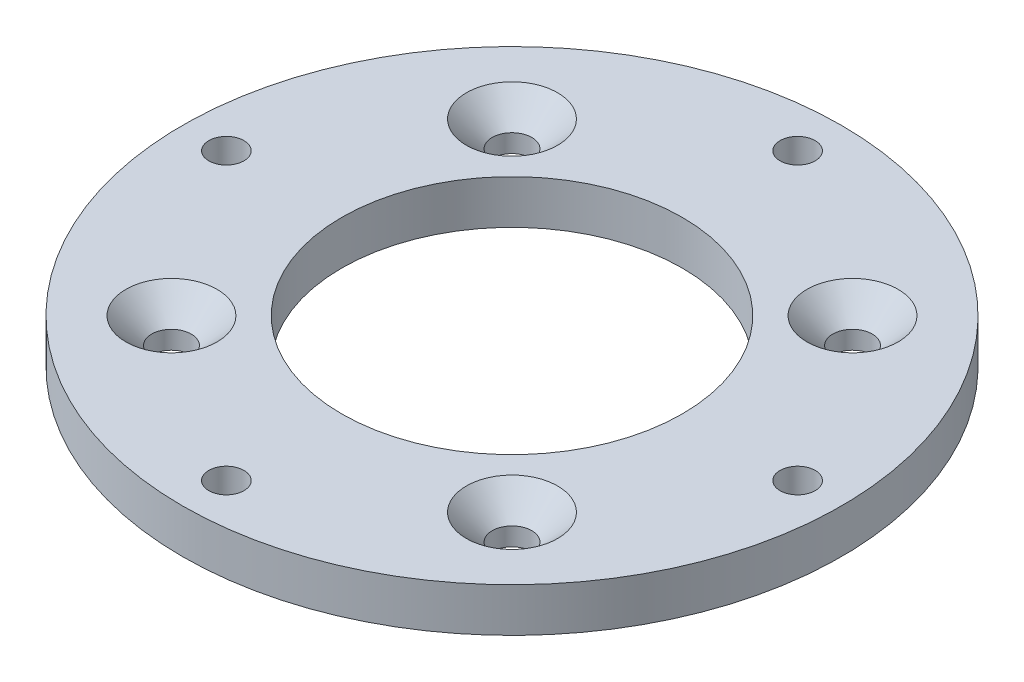
from build123d import *

# Parameters (mm, degrees)
SKETCH1_R                                           = 30
BOSS_EXTRUDE1_DEPTH                                 = 4
SKETCH8_R                                           = 15.5
CUT_EXTRUDE1_DEPTH                                  = 6
CSK_FOR_M3_COUNTERSUNK_FLAT_HEAD_SCR_2_COUNT        = 2
CSK_FOR_M3_COUNTERSUNK_FLAT_HEAD_SCR_2_PITCH        = 31
CSK_FOR_M3_COUNTERSUNK_FLAT_HEAD_SCR_3_COUNT        = 2
CSK_FOR_M3_COUNTERSUNK_FLAT_HEAD_SCR_3_PITCH        = 43.840620434
CSK_FOR_M3_COUNTERSUNK_FLAT_HEAD_SCR_4_COUNT        = 2
CSK_FOR_M3_COUNTERSUNK_FLAT_HEAD_SCR_4_PITCH        = 31
CSK_FOR_M3_COUNTERSUNK_FLAT_HEAD_SCREW3_D           = 3.2
CSK_FOR_M3_COUNTERSUNK_FLAT_HEAD_SCREW3_CSINK_D     = 6.3
CSK_FOR_M3_COUNTERSUNK_FLAT_HEAD_SCREW3_CSINK_ANGLE = 90


with BuildPart() as part:
    # Sketch1 → Boss-Extrude1 (new body)
    with BuildSketch(Plane(origin=(0, 0, 0), x_dir=(1, 0, 0), z_dir=(0, 1, 0))):
        Circle(SKETCH1_R)
    extrude(amount=-BOSS_EXTRUDE1_DEPTH)

    # Sketch8 → Cut-Extrude1 (cut)
    with BuildSketch(Plane.XZ.offset(4)):
        Circle(SKETCH8_R)
    extrude(amount=-CUT_EXTRUDE1_DEPTH, mode=Mode.SUBTRACT)

    # Sketch16 → CSK for M3 Countersunk Flat Head Screw2 (revolve, cut)
    with BuildSketch(Plane(origin=(15.5, 0, 15.5), x_dir=(0, 0, 1), z_dir=(1, 0, 0))):
        Polygon((0, 0), (0, 4), (1.8, 4), (1.8, 2.35), (4.15, 0), align=None)
    csk_for_m3_countersunk_flat_head_screw2 = revolve(axis=Axis((15.5, 6.35, 15.5), (0, -1, 0)), mode=Mode.SUBTRACT)

    # CSK for M3 Countersunk Flat Head Scr 2: CSK for M3 Countersunk Flat Head Screw2 ×2
    with Locations(*[(0, 0, -i * CSK_FOR_M3_COUNTERSUNK_FLAT_HEAD_SCR_2_PITCH) for i in range(1, CSK_FOR_M3_COUNTERSUNK_FLAT_HEAD_SCR_2_COUNT)]):
        add(csk_for_m3_countersunk_flat_head_screw2, mode=Mode.SUBTRACT)

    # CSK for M3 Countersunk Flat Head Scr 3: CSK for M3 Countersunk Flat Head Screw2 ×2
    with Locations(*[Vector(-0.707106781, 0, -0.707106781) * (i * CSK_FOR_M3_COUNTERSUNK_FLAT_HEAD_SCR_3_PITCH) for i in range(1, CSK_FOR_M3_COUNTERSUNK_FLAT_HEAD_SCR_3_COUNT)]):
        add(csk_for_m3_countersunk_flat_head_screw2, mode=Mode.SUBTRACT)

    # CSK for M3 Countersunk Flat Head Scr 4: CSK for M3 Countersunk Flat Head Screw2 ×2
    with Locations(*[(-i * CSK_FOR_M3_COUNTERSUNK_FLAT_HEAD_SCR_4_PITCH, 0, 0) for i in range(1, CSK_FOR_M3_COUNTERSUNK_FLAT_HEAD_SCR_4_COUNT)]):
        add(csk_for_m3_countersunk_flat_head_screw2, mode=Mode.SUBTRACT)

    # CSK for M3 Countersunk Flat Head Screw3 (through all)
    with Locations(Plane.XZ.offset(4)):
        with Locations((0, 26), (26, 0), (0, -26), (-26, 0)):
            CounterSinkHole(CSK_FOR_M3_COUNTERSUNK_FLAT_HEAD_SCREW3_D / 2, CSK_FOR_M3_COUNTERSUNK_FLAT_HEAD_SCREW3_CSINK_D / 2, counter_sink_angle=CSK_FOR_M3_COUNTERSUNK_FLAT_HEAD_SCREW3_CSINK_ANGLE)


solid = part.part
